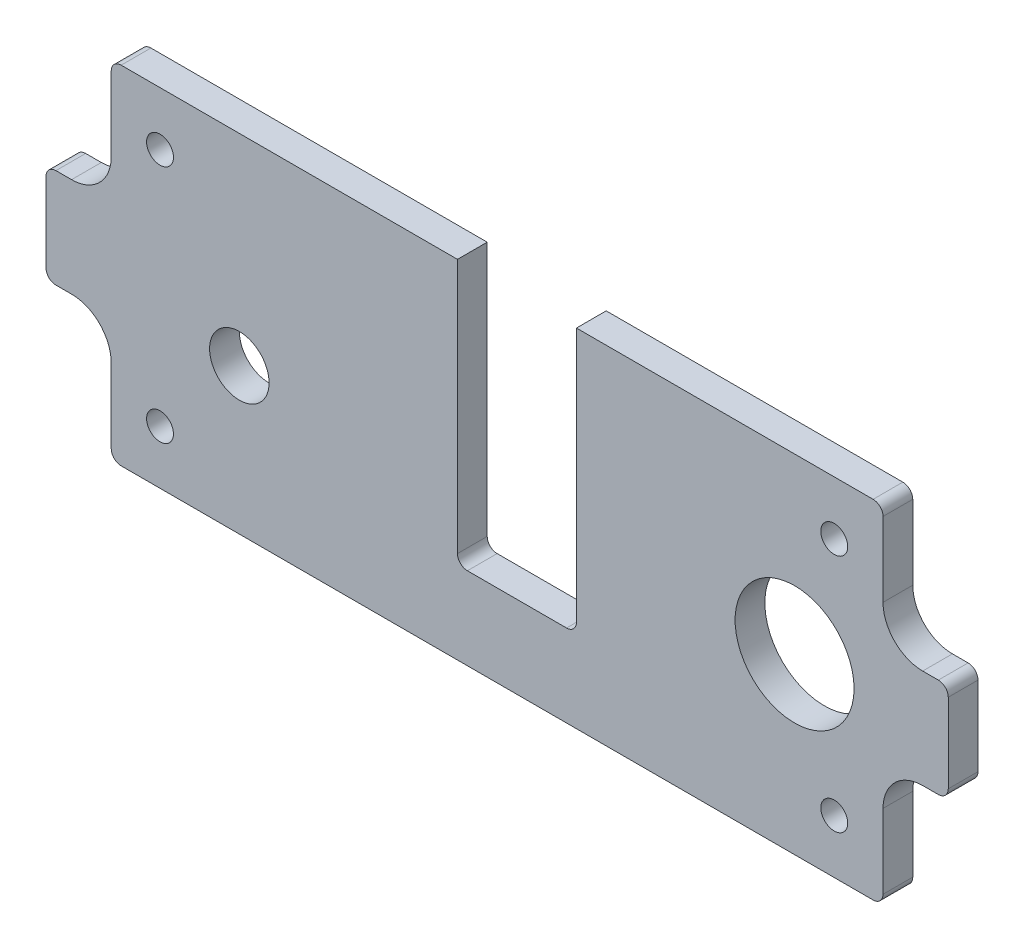
from build123d import *

# Parameters (mm, degrees)
BOSS_EXTRUDE1_DEPTH          = 4.7625
F_3_8_0_375_DIAMETER_HOLE1_D = 9.525
F_3_4_0_75_DIAMETER_HOLE1_D  = 19.05
F_6_CLEARANCE_HOLE1_D        = 4.3053
FILLET1_R                    = 1.5875


with BuildPart() as part:
    # Sketch1 → Boss-Extrude1 (new body)
    with BuildSketch(Plane.XY):
        with BuildLine():
            Line((85.725, 56.35625), (85.725, 13.97))
            Line((85.725, 13.97), (66.675, 13.97))
            Line((66.675, 13.97), (66.675, 56.35625))
            Line((66.675, 56.35625), (11.2395, 56.35625))
            Line((11.2395, 56.35625), (11.2395, 42.8625))
            ThreePointArc((11.2395, 42.8625), (9.379628061, 38.372371939), (4.8895, 36.5125))
            Line((4.8895, 36.5125), (0.79375, 36.5125))
            Line((0.79375, 36.5125), (0.79375, 20.6375))
            Line((0.79375, 20.6375), (4.8895, 20.6375))
            ThreePointArc((4.8895, 20.6375), (9.379628061, 18.777628061), (11.2395, 14.2875))
            Line((11.2395, 14.2875), (11.2395, 0.79375))
            Line((11.2395, 0.79375), (134.8105, 0.79375))
            Line((134.8105, 0.79375), (134.8105, 14.2875))
            ThreePointArc((134.8105, 14.2875), (136.670371939, 18.777628061), (141.1605, 20.6375))
            Line((141.1605, 20.6375), (145.25625, 20.6375))
            Line((145.25625, 20.6375), (145.25625, 36.5125))
            Line((145.25625, 36.5125), (141.1605, 36.5125))
            ThreePointArc((141.1605, 36.5125), (136.670371939, 38.372371939), (134.8105, 42.8625))
            Line((134.8105, 42.8625), (134.8105, 56.35625))
            Line((134.8105, 56.35625), (85.725, 56.35625))
        make_face()
    extrude(amount=BOSS_EXTRUDE1_DEPTH)

    # 3/8 (0.375) Diameter Hole1 (through all)
    with Locations(Plane.XY.offset(4.7625)):
        with Locations((31.75, 24.13)):
            Hole(F_3_8_0_375_DIAMETER_HOLE1_D / 2)

    # 3/4 (0.75) Diameter Hole1 (through all)
    with Locations(Plane.XY.offset(4.7625)):
        with Locations((76.2, 28.575), (120.65, 28.575)):
            Hole(F_3_4_0_75_DIAMETER_HOLE1_D / 2)

    # #6 Clearance Hole1 (through all)
    with Locations(Plane.XY.offset(4.7625)):
        with Locations((19.05, 9.398), (19.05, 47.752), (127, 47.752), (127, 9.398)):
            Hole(F_6_CLEARANCE_HOLE1_D / 2)

    # Fillet1
    fillet1_edges = [part.edges().sort_by_distance(p)[0] for p in [
        (134.8105, 56.35625, 2.38125),
        (145.25625, 36.5125, 2.38125),
        (145.25625, 20.6375, 2.38125),
        (134.8105, 0.79375, 2.38125),
        (11.2395, 0.79375, 2.38125),
        (0.79375, 20.6375, 2.38125),
        (0.79375, 36.5125, 2.38125),
        (11.2395, 56.35625, 2.38125),
        (66.675, 13.97, 2.38125),
        (85.725, 13.97, 2.38125),
    ]]
    fillet(fillet1_edges, radius=FILLET1_R)


solid = part.part
